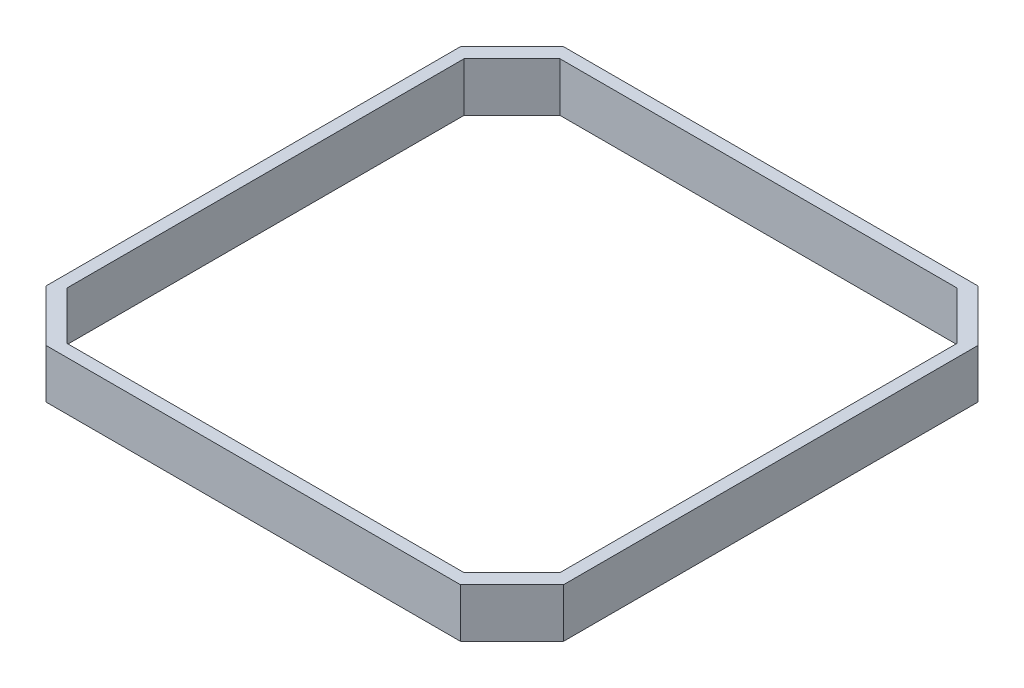
from build123d import *

# Parameters (mm, degrees)
SKETCH_1_W      = 42.2
SKETCH_1_H      = 42.2
SKETCH_1_W_2    = 40.2
SKETCH_1_H_2    = 40.2
EXTRUDE_1_DEPTH = 4
CHAMFER_1_SIZE  = 3.9
CHAMFER_2_SIZE  = 4.2


with BuildPart() as part:
    # 草图1 → 凸台-拉伸1 (new body)
    with BuildSketch(Plane(origin=(0, 0, 0), x_dir=(1, 0, 0), z_dir=(0, 1, 0))):
        with Locations((20.1, 20.1)):
            Rectangle(SKETCH_1_W, SKETCH_1_H)
        with Locations((20.1, 20.1)):
            Rectangle(SKETCH_1_W_2, SKETCH_1_H_2, mode=Mode.SUBTRACT)
    extrude(amount=EXTRUDE_1_DEPTH)

    # 倒角1
    chamfer_1_edges = [part.edges().sort_by_distance(p)[0] for p in [
        (0, 2, -40.2),
        (0, 2, 0),
        (40.2, 2, 0),
        (40.2, 2, -40.2),
    ]]
    chamfer(chamfer_1_edges, length=CHAMFER_1_SIZE)

    # 倒角2
    chamfer_2_edges = [part.edges().sort_by_distance(p)[0] for p in [
        (-1, 2, 1),
        (-1, 2, -41.2),
        (41.2, 2, -41.2),
        (41.2, 2, 1),
    ]]
    chamfer(chamfer_2_edges, length=CHAMFER_2_SIZE)


solid = part.part
